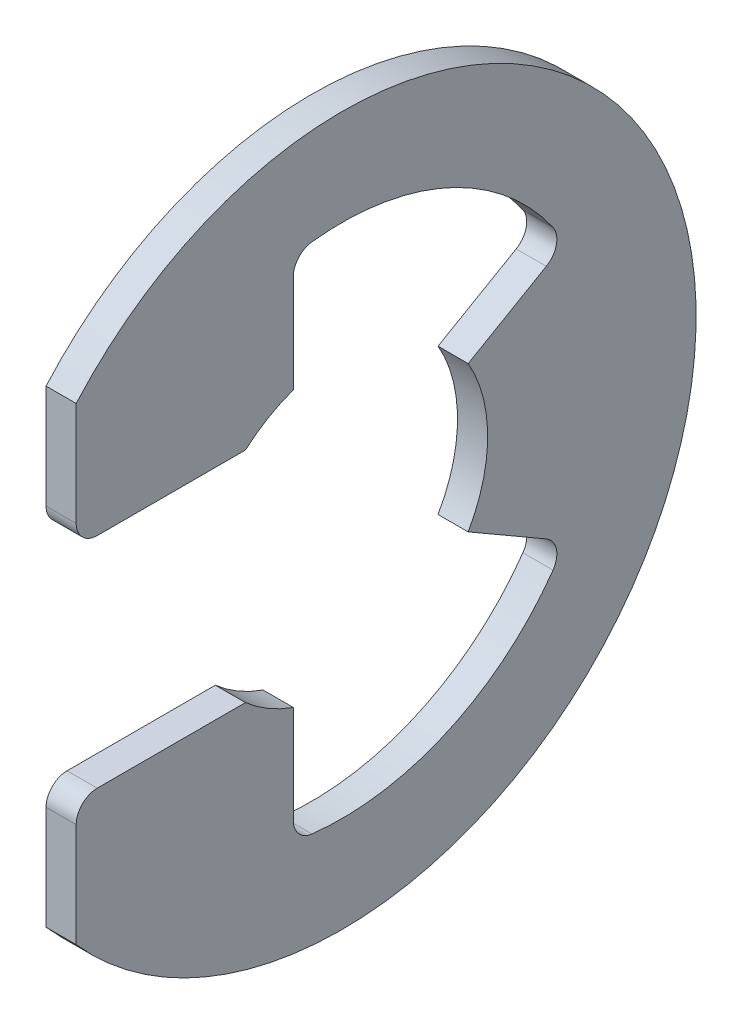
from build123d import *

# Parameters (mm, degrees)
EXTRUDE1_DEPTH = 0.3175
FILLET1_R      = 0.4445


with BuildPart() as part:
    # Sketch1 → Extrude1 (new body, symmetric)
    with BuildSketch(Plane(origin=(0, 0, 0), x_dir=(0, 0, -1), z_dir=(1, 0, 0))):
        with BuildLine():
            Line((-2.03286302, 2.30505), (-5.6007, 2.30505))
            Line((-5.6007, 2.30505), (-5.6007, 4.939353123))
            ThreePointArc((-5.6007, 4.939353123), (7.4676, 0), (-5.6007, -4.939353123))
            Line((-5.6007, -4.939353123), (-5.6007, -2.30505))
            Line((-5.6007, -2.30505), (-2.03286302, -2.30505))
            ThreePointArc((-2.03286302, -2.30505), (-1.557113921, -2.649751648), (-1.024466667, -2.897629308))
            Line((-1.024466667, -2.897629308), (-1.024466667, -5.343190414))
            ThreePointArc((-1.024466667, -5.343190414), (2.262460607, -4.947776041), (4.711625177, -2.720258065))
            Line((4.711625177, -2.720258065), (2.661642476, -1.5367))
            ThreePointArc((2.661642476, -1.5367), (3.0734, 0), (2.661642476, 1.5367))
            Line((2.661642476, 1.5367), (4.711625177, 2.720258065))
            ThreePointArc((4.711625177, 2.720258065), (2.262460607, 4.947776041), (-1.024466667, 5.343190414))
            Line((-1.024466667, 5.343190414), (-1.024466667, 2.897629308))
            ThreePointArc((-1.024466667, 2.897629308), (-1.557113921, 2.649751648), (-2.03286302, 2.30505))
        make_face()
    extrude(amount=EXTRUDE1_DEPTH, both=True)

    # Fillet1
    fillet1_edges = [part.edges().sort_by_distance(p)[0] for p in [
        (0, -2.30505, 5.6007),
        (0, -5.343190414, 1.024466667),
        (0, -2.720258065, -4.711625177),
        (0, 2.720258065, -4.711625177),
        (0, 5.343190414, 1.024466667),
        (0, 2.30505, 5.6007),
    ]]
    fillet(fillet1_edges, radius=FILLET1_R)


solid = part.part
